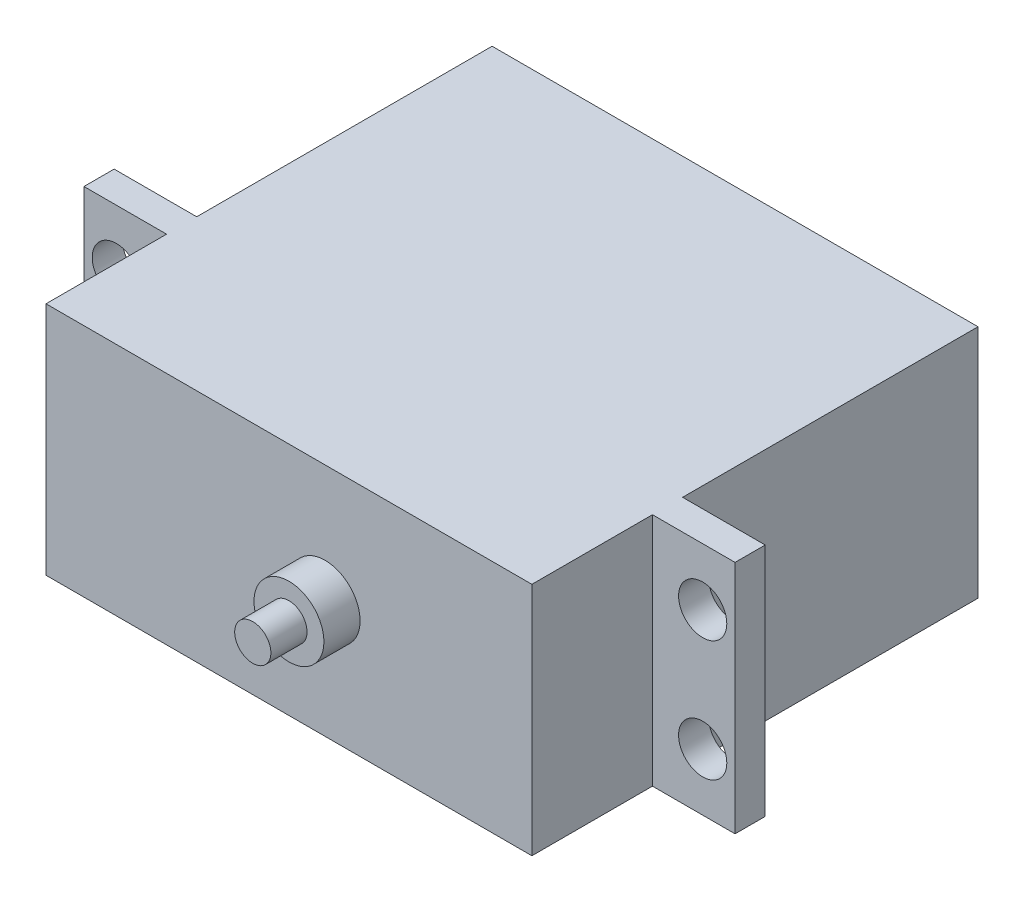
from build123d import *

# Parameters (mm, degrees)
SKETCH_1_W      = 40.3
SKETCH_1_H      = 19.5
EXTRUDE_1_DEPTH = 37
SKETCH_2_R      = 2.9
EXTRUDE_2_DEPTH = 3
SKETCH_3_R      = 1.5
EXTRUDE_3_DEPTH = 3
SKETCH_4_W      = 54
SKETCH_4_H      = 19.5
EXTRUDE_4_DEPTH = 2.5
MM_1_D          = 4
MM_1_DEPTH      = 7.5
MM_1_TIP        = 1.201721238


with BuildPart() as part:
    # 草图1 → 凸台-拉伸1 (new body)
    with BuildSketch(Plane.XY):
        Rectangle(SKETCH_1_W, SKETCH_1_H)
    extrude(amount=EXTRUDE_1_DEPTH)

    # 草图2 → 凸台-拉伸2 (add)
    with BuildSketch(Plane.XY.offset(37)):
        with Locations((3, 0)):
            Circle(SKETCH_2_R)
    extrude(amount=EXTRUDE_2_DEPTH)

    # 草图3 → 凸台-拉伸3 (add)
    with BuildSketch(Plane.XY.offset(40)):
        with Locations((3, 0)):
            Circle(SKETCH_3_R)
    extrude(amount=EXTRUDE_3_DEPTH)

    # 草图4 → 凸台-拉伸4 (add)
    with BuildSketch(Plane.XY.offset(27)):
        Rectangle(SKETCH_4_W, SKETCH_4_H)
    extrude(amount=-EXTRUDE_4_DEPTH)

    # 大小mm 暗销孔1
    with Locations(Plane.XY.offset(27)):
        with Locations((-24.315, 5), (-24.315, -5), (24.315, -5), (24.315, 5)):
            Hole(MM_1_D / 2, depth=MM_1_DEPTH)
            with Locations((0, 0, -(MM_1_DEPTH + MM_1_TIP / 2))):  # 118° drill point
                Cone(0, MM_1_D / 2, MM_1_TIP, mode=Mode.SUBTRACT)


solid = part.part
